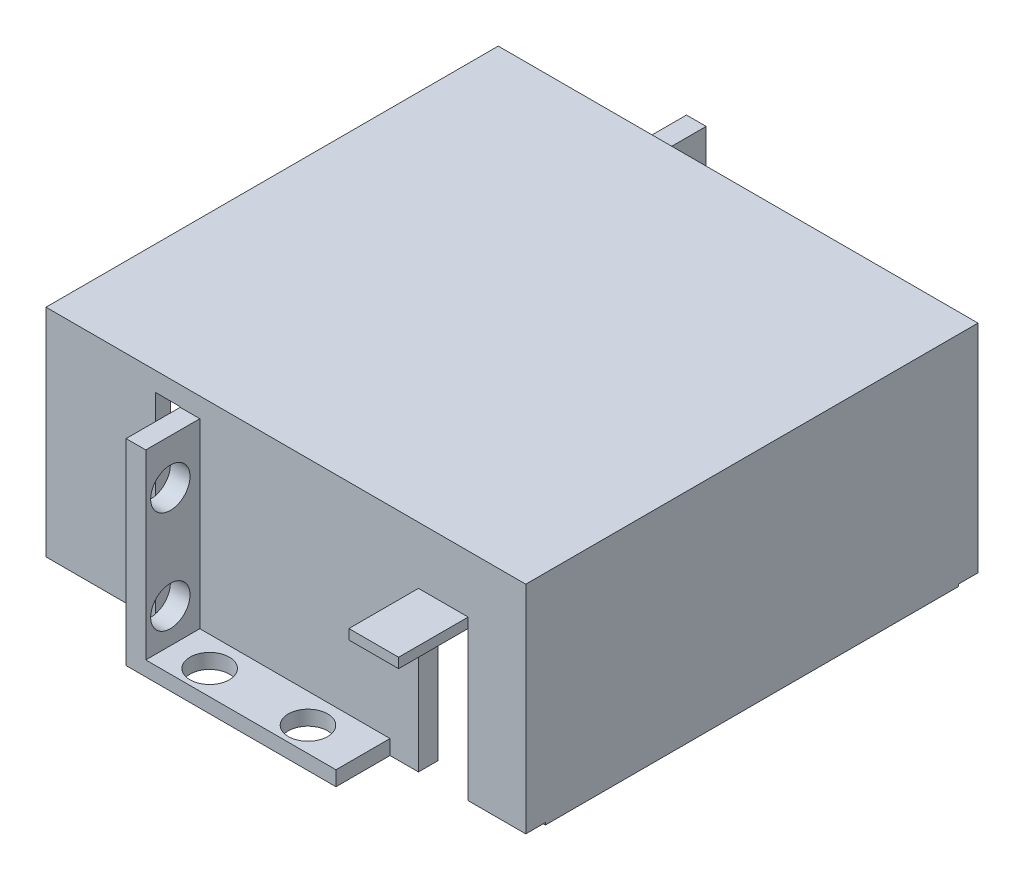
from build123d import *

# Parameters (mm, degrees)
SKETCH2_W                 = 7.5
SKETCH2_H                 = 20
SKETCH2_R                 = 2
BOSS_EXTRUDE1_DEPTH       = 2
SKETCH4_W                 = 21
SKETCH4_H                 = 20
BOSS_EXTRUDE2_DEPTH       = 2
SKETCH5_W                 = 21
SKETCH5_H                 = 46
BOSS_EXTRUDE3_DEPTH       = 2
SKETCH6_W                 = 21
SKETCH6_H                 = 2
BOSS_EXTRUDE4_DEPTH       = 22
SKETCH7_W                 = 6.5
SKETCH7_H                 = 20
SKETCH7_R                 = 2
BOSS_EXTRUDE7_DEPTH       = 2
SKETCH8_W                 = 20
SKETCH8_H                 = 6.5
SKETCH8_R                 = 2
BOSS_EXTRUDE9_DEPTH       = 1.5
SKETCH9_R                 = 2
BOSS_EXTRUDE10_DEPTH      = 1.5
SCALE1_SCALE              = 0.98
SCALE2_SCALE              = 0.98
SCALE3_SCALE              = 1.03
BOSS_EXTRUDE11_DEPTH      = 14
SKETCH13_W                = 1
SKETCH13_H                = 41.546904
BOSS_EXTRUDE12_DEPTH      = 20
SKETCH15_W                = 13.656209454
SKETCH15_H                = 5.440666
CUT_EXTRUDE1_DEPTH        = 20
SKETCH16_W                = 13.65620945
SKETCH16_H                = 5.440666
CUT_EXTRUDE2_DEPTH        = 20
BOSS_EXTRUDE13_DEPTH      = 13.5
SKETCH18_W                = 2.5
SKETCH18_H                = 19.843095219
CUT_EXTRUDE3_DEPTH        = 51.944418
SKETCH19_W                = 1
SKETCH19_H                = 41.546904
BOSS_EXTRUDE14_DEPTH      = 19.78424
CUT_EXTRUDE4_REACH        = 52.944
SKETCH20_W                = 5
SKETCH20_H                = 15
SKETCH21_W                = 10
SKETCH21_H                = 14
CUT_EXTRUDE5_DEPTH        = 19.5
SKETCH22_W                = 5
SKETCH22_H                = 1
BOSS_EXTRUDE15_DEPTH      = 7
BOSS_EXTRUDE15_DEPTH_BACK = 2
SKETCH23_W                = 1.2
SKETCH23_H                = 19.843095219
CUT_EXTRUDE9_DEPTH        = 44


with BuildPart() as part:
    # Sketch2 → Boss-Extrude1 (new body)
    with BuildSketch(Plane(origin=(0, 0, 0), x_dir=(0, 0, -1), z_dir=(1, 0, 0))):
        with Locations((-3.75, -10)):
            Rectangle(SKETCH2_W, SKETCH2_H)
        with Locations((-5, -4.580102725)):
            Circle(SKETCH2_R, mode=Mode.SUBTRACT)
        with Locations((-5, -15)):
            Circle(SKETCH2_R, mode=Mode.SUBTRACT)
    extrude(amount=BOSS_EXTRUDE1_DEPTH)

    # Sketch4 → Boss-Extrude2 (add)
    with BuildSketch(Plane.XY):
        with Locations((10.5, -10)):
            Rectangle(SKETCH4_W, SKETCH4_H)
    extrude(amount=BOSS_EXTRUDE2_DEPTH)

    # Sketch5 → Boss-Extrude3 (add)
    with BuildSketch(Plane(origin=(0, 0, 0), x_dir=(1, 0, 0), z_dir=(0, 1, 0))):
        with Locations((10.5, 21)):
            Rectangle(SKETCH5_W, SKETCH5_H)
    extrude(amount=BOSS_EXTRUDE3_DEPTH)

    # Sketch6 → Boss-Extrude4 (add)
    with BuildSketch(Plane(origin=(0, 2, 0), x_dir=(1, 0, 0), z_dir=(0, 1, 0))):
        with Locations((10.5, 43)):
            Rectangle(SKETCH6_W, SKETCH6_H)
    extrude(amount=-BOSS_EXTRUDE4_DEPTH)

    # Sketch7 → Boss-Extrude7 (add)
    with BuildSketch(Plane.ZY):
        with Locations((-46.25, -10)):
            Rectangle(SKETCH7_W, SKETCH7_H)
        with Locations((-47, -5)):
            Circle(SKETCH7_R, mode=Mode.SUBTRACT)
        with Locations((-47, -15)):
            Circle(SKETCH7_R, mode=Mode.SUBTRACT)
    extrude(amount=-BOSS_EXTRUDE7_DEPTH)

    # Sketch8 → Boss-Extrude9 (add)
    with BuildSketch(Plane.XZ.offset(20)):
        with Locations((11, -46.25)):
            Rectangle(SKETCH8_W, SKETCH8_H)
        with Locations((6, -47)):
            Circle(SKETCH8_R, mode=Mode.SUBTRACT)
        with Locations((16, -47)):
            Circle(SKETCH8_R, mode=Mode.SUBTRACT)
    extrude(amount=-BOSS_EXTRUDE9_DEPTH)

    # Sketch9 → Boss-Extrude10 (add)
    with BuildSketch(Plane.XZ.offset(20)):
        Polygon((21, 2), (21, 7.5), (16, 7.5), (6, 7.5), (2, 7.5), (2, 2), align=None)
        with Locations((6, 5)):
            Circle(SKETCH9_R, mode=Mode.SUBTRACT)
        with Locations((16, 5)):
            Circle(SKETCH9_R, mode=Mode.SUBTRACT)
    extrude(amount=-BOSS_EXTRUDE10_DEPTH)


with BuildPart() as part_1:
    # Scale1: scaled about (9.7960723, -5.455619142, -21)
    add(part.part.scale(SCALE1_SCALE).moved(Location((0.195921446, -0.109112383, -0.42))))


with BuildPart() as part_2:
    # Scale2: scaled about (9.7960723, -5.455619142, -21)
    add(part_1.part.scale(SCALE2_SCALE).moved(Location((0.195921446, -0.109112383, -0.42))))


with BuildPart() as part_3:
    # Scale3: scaled about (9.7960723, -5.455619142, -21)
    add(part_2.part.scale(SCALE3_SCALE).moved(Location((-0.293882169, 0.163668574, 0.63))))

    # Sketch11 → Boss-Extrude11 (add)
    with BuildSketch(Plane(origin=(20.879132028, 0, 0), x_dir=(0, 0, -1), z_dir=(1, 0, 0))):
        Polygon((-1.751876, 1.919568781), (43.751876, 1.919568781), (43.751876, -18.359277219), (49.192542, -18.359277219), (49.192542, -19.843095219), (41.773452, -19.843095219), (41.773452, -0.058855219), (0.226548, -0.058855219), (0.226548, -19.843095219), (-7.192542, -19.843095219), (-7.192542, -18.359277219), (-1.751876, -18.359277219), align=None)
    extrude(amount=BOSS_EXTRUDE11_DEPTH)

    # Sketch13 → Boss-Extrude12 (add)
    with BuildSketch(Plane(origin=(0, -0.058855219, 0), x_dir=(-1, 0, 0), z_dir=(0, -1, 0))):
        with Locations((-34.379132028, 21)):
            Rectangle(SKETCH13_W, SKETCH13_H)
    extrude(amount=BOSS_EXTRUDE12_DEPTH)

    # Sketch15 → Cut-Extrude1 (cut)
    with BuildSketch(Plane(origin=(0, -18.359277219, 0), x_dir=(1, 0, 0), z_dir=(0, 1, 0))):
        with Locations((28.051027301, 46.472209)):
            Rectangle(SKETCH15_W, SKETCH15_H)
    extrude(amount=-CUT_EXTRUDE1_DEPTH, mode=Mode.SUBTRACT)

    # Sketch16 → Cut-Extrude2 (cut)
    with BuildSketch(Plane(origin=(0, -18.359277219, 0), x_dir=(1, 0, 0), z_dir=(0, 1, 0))):
        with Locations((28.051027303, -4.472209)):
            Rectangle(SKETCH16_W, SKETCH16_H)
    extrude(amount=-CUT_EXTRUDE2_DEPTH, mode=Mode.SUBTRACT)

    # Sketch17 → Boss-Extrude13 (add)
    with BuildSketch(Plane.ZY.offset(-0.105680028)):
        Polygon((1.751876, 1.919568781), (-43.751876, 1.919568781), (-43.751876, -0.058855219), (-43.751876, -19.843095219), (-41.773452, -19.843095219), (-41.773452, -0.058855219), (-0.226548, -0.058855219), (-0.226548, -19.843095219), (1.751876, -19.843095219), (1.751876, -0.058855219), align=None)
    extrude(amount=BOSS_EXTRUDE13_DEPTH)

    # Sketch18 → Cut-Extrude3 (cut, through all)
    with BuildSketch(Plane.XY.offset(1.751876)):
        with Locations((-1.144319972, -9.92154761)):
            Rectangle(SKETCH18_W, SKETCH18_H)
    extrude(amount=-CUT_EXTRUDE3_DEPTH, mode=Mode.SUBTRACT)

    # Sketch19 → Boss-Extrude14 (add)
    with BuildSketch(Plane.XZ.offset(0.058855219)):
        with Locations((-12.894319972, -21)):
            Rectangle(SKETCH19_W, SKETCH19_H)
    extrude(amount=BOSS_EXTRUDE14_DEPTH)

    # Sketch20 → Cut-Extrude4 (cut, up to next)
    with BuildSketch(Plane.XY.offset(1.751876), mode=Mode.PRIVATE) as cut_extrude4_sk1:
        with Locations((26.584104028, -12.343095219)):
            Rectangle(SKETCH20_W, SKETCH20_H)
    cut_extrude4_tool1 = extrude(cut_extrude4_sk1.sketch, amount=-CUT_EXTRUDE4_REACH, mode=Mode.PRIVATE) & part_3.part
    add(cut_extrude4_tool1.solids().sort_by_distance((26.584104, -12.343095, 1.751876))[0], mode=Mode.SUBTRACT)

    # Sketch21 → Cut-Extrude5 (cut)
    with BuildSketch(Plane.ZY.offset(13.394319972)):
        with Locations((-9.248124, -12.843095219)):
            Rectangle(SKETCH21_W, SKETCH21_H)
    extrude(amount=-CUT_EXTRUDE5_DEPTH, mode=Mode.SUBTRACT)

    # Sketch22 → Boss-Extrude15 (add, two sides)
    with BuildSketch(Plane.XY.offset(1.751876)) as boss_extrude15_sk:
        with Locations((26.584104028, -4.343095219)):
            Rectangle(SKETCH22_W, SKETCH22_H)
    extrude(amount=BOSS_EXTRUDE15_DEPTH)
    extrude(boss_extrude15_sk.sketch, amount=-BOSS_EXTRUDE15_DEPTH_BACK)

    # Sketch23 → Cut-Extrude9 (cut)
    with BuildSketch(Plane(origin=(0, 0, -43.751876), x_dir=(-1, 0, 0), z_dir=(0, 0, -1))):
        with Locations((2.994319972, -9.92154761)):
            Rectangle(SKETCH23_W, SKETCH23_H)
    extrude(amount=-CUT_EXTRUDE9_DEPTH, mode=Mode.SUBTRACT)


solid = part_3.part
